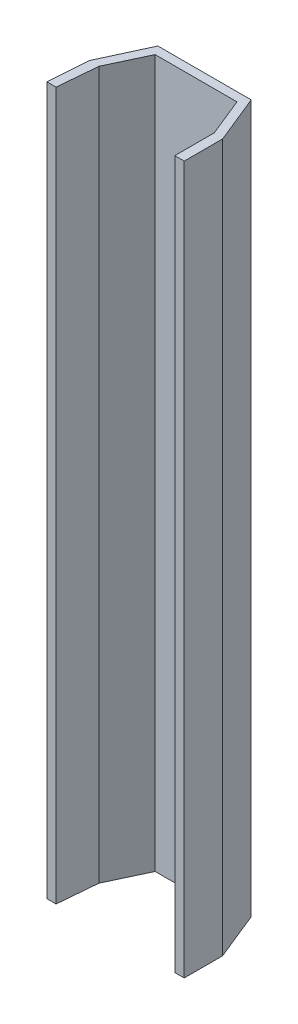
from build123d import *

# Parameters (mm, degrees)
BOSS_EXTRUDE1_DEPTH = 254


with BuildPart() as part:
    # Sketch1 → Boss-Extrude1 (new body)
    with BuildSketch(Plane(origin=(0, 0, 0), x_dir=(1, 0, 0), z_dir=(0, 1, 0))):
        Polygon((0, 0), (1.225466559, 14.161273274), (7.659875515, 27.894414778), (37.046877614, 27.894414778), (42.616962979, 14.161273274), (42.616962979, 0), (46.003087234, 0), (46.003087234, 13.78561588), (38.99685671, 31.059598032), (5.493882431, 31.059598032), (-2.316363335, 14.161273274), (-3.334758131, 0), align=None)
    extrude(amount=BOSS_EXTRUDE1_DEPTH)


solid = part.part
